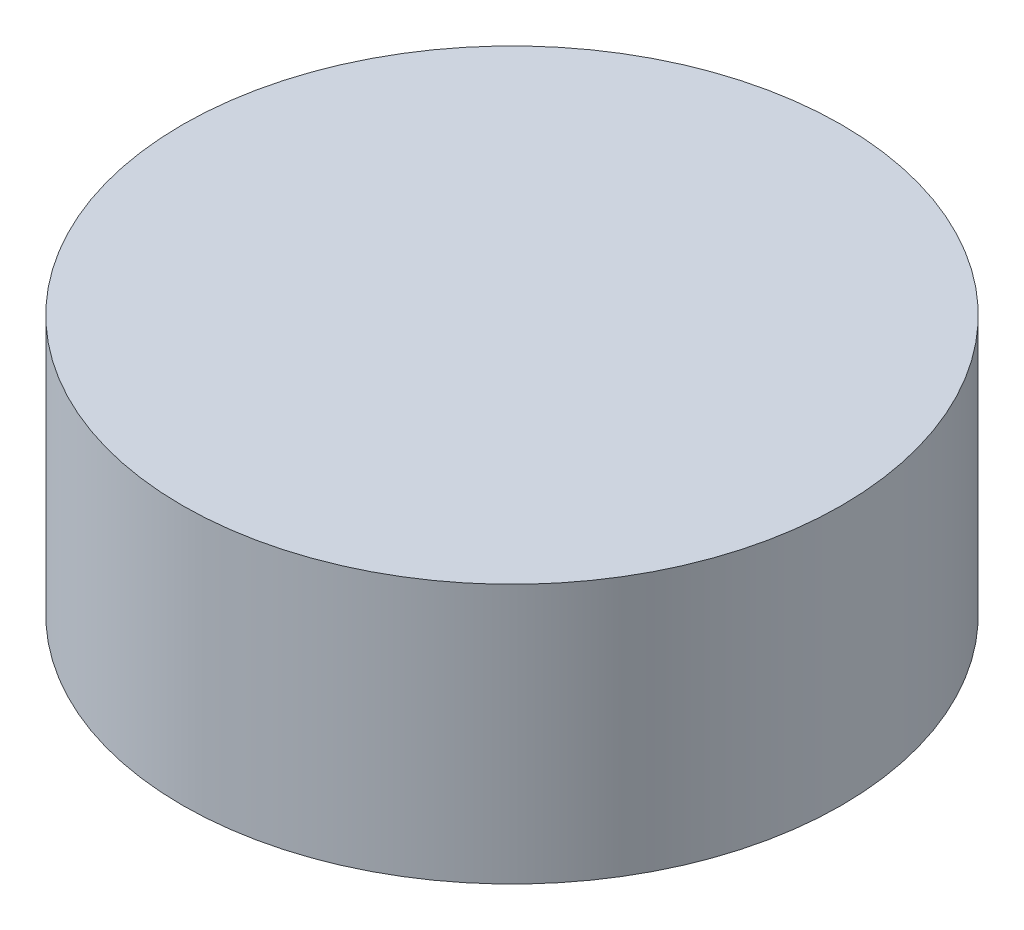
from build123d import *

# Parameters (mm, degrees)
SKETCH_1_R      = 25.4
EXTRUDE_1_DEPTH = 20


with BuildPart() as part:
    # ｽｹｯﾁ1 → ﾎﾞｽ - 押し出し1 (new body)
    with BuildSketch(Plane(origin=(0, 0, 0), x_dir=(1, 0, 0), z_dir=(0, 1, 0))):
        Circle(SKETCH_1_R)
    extrude(amount=EXTRUDE_1_DEPTH)


solid = part.part
